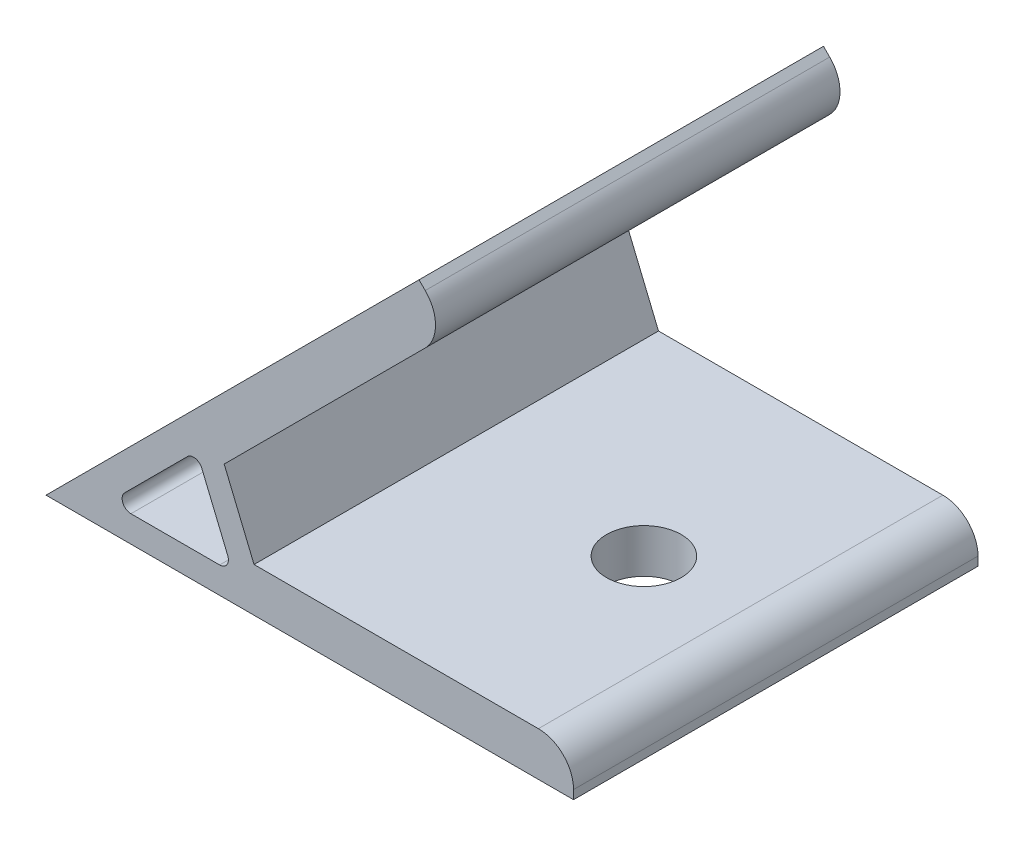
from build123d import *

# Parameters (mm, degrees)
EXTRUDE_1_DEPTH     = 23
SKETCH_2_R          = 4.25
CUT_EXTRUDE_1_DEPTH = 5
SKETCH_3_R          = 4.25
CUT_EXTRUDE_2_DEPTH = 5
FILLET_1_R          = 4
FILLET_2_R          = 1


with BuildPart() as part:
    # Эскиз1 → Бобышка-Вытянуть1 (new body, symmetric)
    with BuildSketch(Plane.XY):
        Polygon((0, 0), (42.426406871, 42.426406871), (45.961940777, 38.890872965), (20.266663343, 13.195595531), (23.661390163, 5), (60, 5), (60, 0), align=None)
        Polygon((17.142135624, 12.899494937), (21.242640687, 3), (7.242640687, 3), align=None, mode=Mode.SUBTRACT)
    extrude(amount=EXTRUDE_1_DEPTH, both=True)

    # Эскиз2 → Вырез-Вытянуть1 (cut)
    with BuildSketch(Plane(origin=(0, 0, 0), x_dir=(0, 0, 1), z_dir=(-0.707106781, 0.707106781, 0))):
        with Locations(Location((0, 45, 0), (0, 0, 270))):  # turned: the seam where the file's is
            Circle(SKETCH_2_R)
    extrude(amount=-CUT_EXTRUDE_1_DEPTH, mode=Mode.SUBTRACT)

    # Эскиз3 → Вырез-Вытянуть2 (cut)
    with BuildSketch(Plane.XZ):
        with Locations(Location((45, 0, 0), (0, 0, 270))):  # turned: the seam where the file's is
            Circle(SKETCH_3_R)
    extrude(amount=-CUT_EXTRUDE_2_DEPTH, mode=Mode.SUBTRACT)

    # Скругление1
    fillet_1_edges = [part.edges().sort_by_distance(p)[0] for p in [
        (45.961940777, 38.890872965, 0),
        (60, 5, 0),
    ]]
    fillet(fillet_1_edges, radius=FILLET_1_R)

    # Скругление2
    fillet_2_edges = [part.edges().sort_by_distance(p)[0] for p in [
        (17.142135624, 12.899494937, 0),
        (7.242640687, 3, 0),
        (21.242640687, 3, 0),
    ]]
    fillet(fillet_2_edges, radius=FILLET_2_R)


solid = part.part
